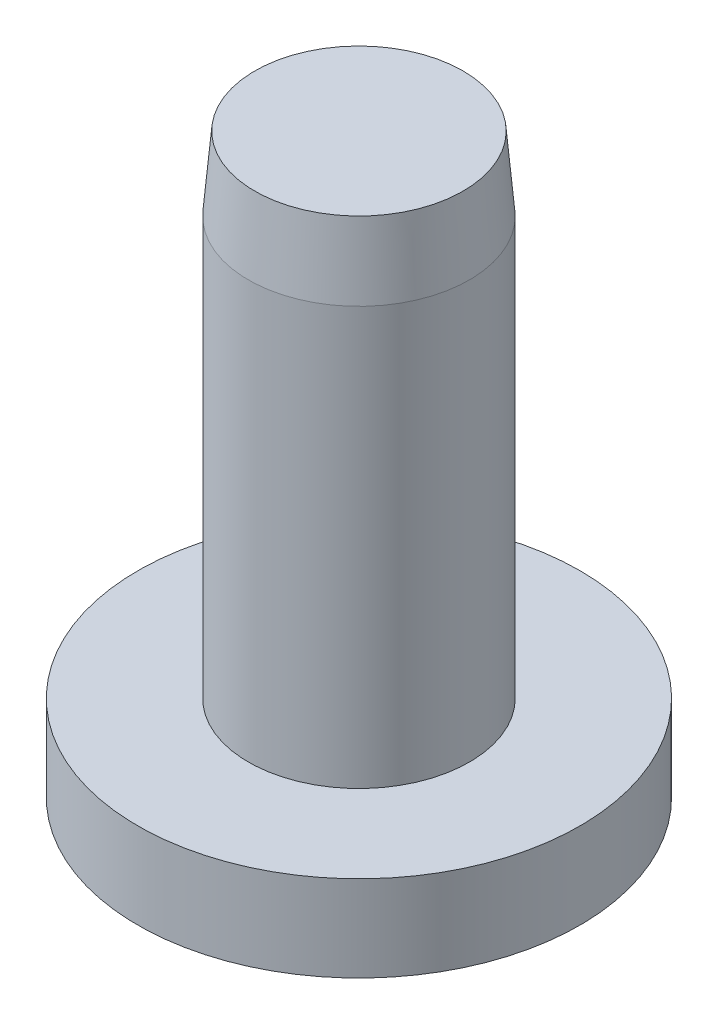
from build123d import *

# Parameters (mm, degrees)
CHAMFER_1_SIZE  = 0.26
CHAMFER_1_SIZE2 = 3


with BuildPart() as part:
    # Эскиз1 → Повернуть1 (revolve)
    with BuildSketch(Plane.XY):
        Polygon((0, 0), (0, 21.5), (-4.5, 21.5), (-4.5, 1.5), (-9, 1.5), (-9, -2), (-8, -2), (-8, 0), align=None)
    revolve(axis=Axis((0, 0, 0), (0, 1, 0)))

    # Фаска1
    chamfer_1_edges = [part.edges().sort_by_distance(p)[0] for p in [
        (4.5, 21.5, 0),
    ]]
    chamfer_1_side = [part.faces().sort_by_distance(p)[0] for p in [
        (0, 21.5, 0),
    ]]
    chamfer(chamfer_1_edges, length=CHAMFER_1_SIZE, length2=CHAMFER_1_SIZE2, reference=chamfer_1_side[0])


solid = part.part
